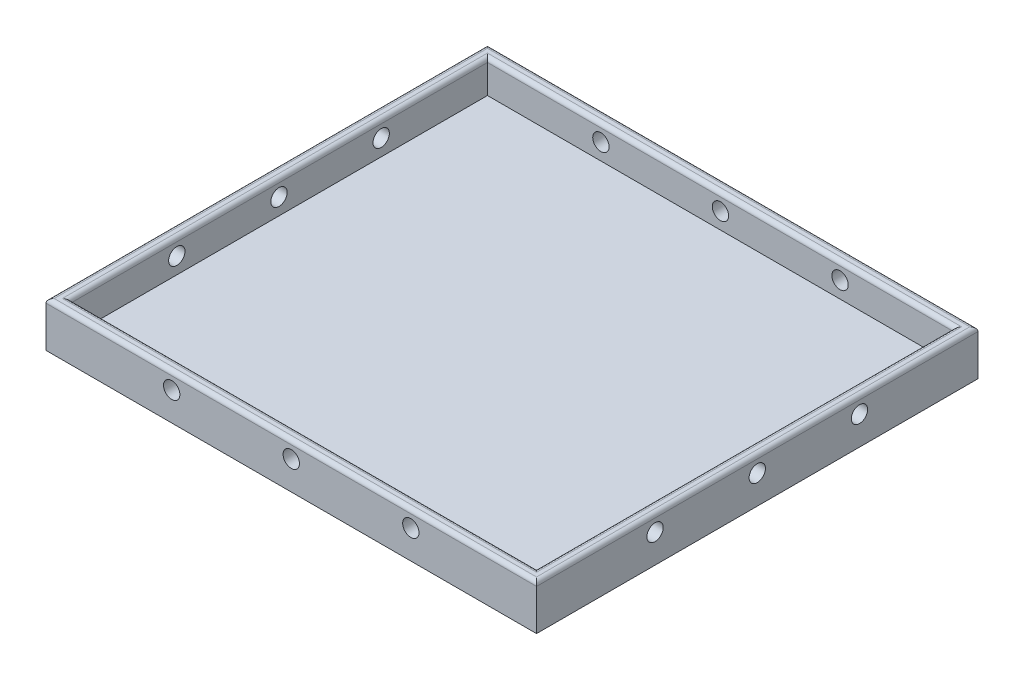
from build123d import *

# Parameters (mm, degrees)
SKETCH1_W               = 120
SKETCH1_H               = 108
BOSS_EXTRUDE1_DEPTH     = 11
SKETCH4_W               = 114
SKETCH4_H               = 102
CUT_EXTRUDE1_DEPTH      = 8
SKETCH6_R               = 1.999999993
SKETCH6_R_2             = 2
CUT_EXTRUDE6_DEPTH      = 118
CUT_EXTRUDE6_DEPTH_BACK = 4
SKETCH5_R               = 2
CUT_EXTRUDE5_DEPTH      = 106
CUT_EXTRUDE5_DEPTH_BACK = 4
FILLET2_R               = 1


with BuildPart() as part:
    # Sketch1 → Boss-Extrude1 (new body)
    with BuildSketch(Plane(origin=(0, 0, 0), x_dir=(1, 0, 0), z_dir=(0, 1, 0))):
        with Locations((-141.609907121, 23.894736842)):
            Rectangle(SKETCH1_W, SKETCH1_H)
    extrude(amount=BOSS_EXTRUDE1_DEPTH)

    # Sketch4 → Cut-Extrude1 (cut)
    with BuildSketch(Plane(origin=(0, 11, 0), x_dir=(1, 0, 0), z_dir=(0, 1, 0))):
        with Locations((-141.609907121, 23.894736842)):
            Rectangle(SKETCH4_W, SKETCH4_H)
    extrude(amount=-CUT_EXTRUDE1_DEPTH, mode=Mode.SUBTRACT)

    # Sketch6 → Cut-Extrude6 (cut, two sides)
    with BuildSketch(Plane(origin=(-198.609907121, 0, 0), x_dir=(0, 0, -1), z_dir=(1, 0, 0))) as cut_extrude6_sk:
        with Locations((-1.105263158, 6.999999977)):
            Circle(SKETCH6_R)
        with Locations((23.894736842, 6.999999977)):
            Circle(SKETCH6_R_2)
        with Locations((48.894736842, 7)):
            Circle(SKETCH6_R_2)
    extrude(amount=CUT_EXTRUDE6_DEPTH, mode=Mode.SUBTRACT)
    extrude(cut_extrude6_sk.sketch, amount=-CUT_EXTRUDE6_DEPTH_BACK, mode=Mode.SUBTRACT)

    # Sketch5 → Cut-Extrude5 (cut, two sides)
    with BuildSketch(Plane.XY.offset(-74.894736842)) as cut_extrude5_sk:
        with Locations((-170.859907121, 7)):
            Circle(SKETCH5_R)
        with Locations((-141.609907121, 7)):
            Circle(SKETCH5_R)
        with Locations((-112.359907121, 7)):
            Circle(SKETCH5_R)
    extrude(amount=CUT_EXTRUDE5_DEPTH, mode=Mode.SUBTRACT)
    extrude(cut_extrude5_sk.sketch, amount=-CUT_EXTRUDE5_DEPTH_BACK, mode=Mode.SUBTRACT)

    # Fillet2
    fillet2_edges = [part.edges().sort_by_distance(p)[0] for p in [
        (-81.609907121, 11, -23.894736842),
        (-141.609907121, 11, -77.894736842),
        (-198.609907121, 11, -23.894736842),
        (-141.609907121, 11, 27.105263158),
        (-84.609907121, 11, -23.894736842),
        (-141.609907121, 11, -74.894736842),
        (-201.609907121, 11, -23.894736842),
        (-141.609907121, 11, 30.105263158),
    ]]
    fillet(fillet2_edges, radius=FILLET2_R)


solid = part.part
